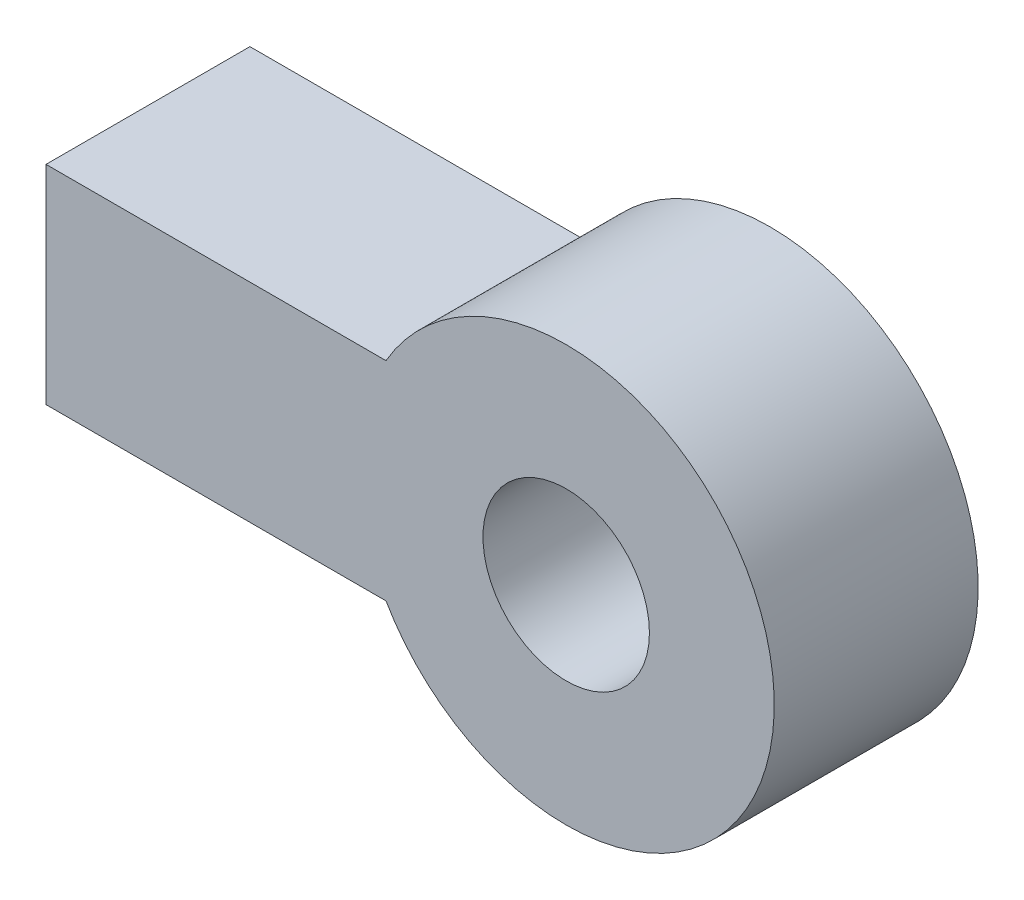
from build123d import *

# Parameters (mm, degrees)
BOSS_EXTRUDE2_DEPTH = 12.446
SKETCH4_R           = 2.54
CUT_EXTRUDE1_DEPTH  = 13.446
SKETCH5_R           = 5.08
CUT_EXTRUDE2_DEPTH  = 10.16


with BuildPart() as part:
    # Sketch3 → Boss-Extrude2 (new body)
    with BuildSketch(Plane.XY):
        with BuildLine():
            Line((-10.998522628, -6.35), (-19.05, -6.35))
            Line((-19.05, -6.35), (-31.75, -6.35))
            Line((-31.75, -6.35), (-31.75, 6.35))
            Line((-31.75, 6.35), (-19.05, 6.35))
            Line((-19.05, 6.35), (-10.998522628, 6.35))
            ThreePointArc((-10.998522628, 6.35), (12.7, 0), (-10.998522628, -6.35))
        make_face()
    extrude(amount=BOSS_EXTRUDE2_DEPTH)

    # Sketch4 → Cut-Extrude1 (cut, through all)
    with BuildSketch(Plane(origin=(0, 0, 0), x_dir=(-1, 0, 0), z_dir=(0, 0, -1))):
        Circle(SKETCH4_R)
    extrude(amount=-CUT_EXTRUDE1_DEPTH, mode=Mode.SUBTRACT)

    # Sketch5 → Cut-Extrude2 (cut)
    with BuildSketch(Plane.XY.offset(12.446)):
        Circle(SKETCH5_R)
    extrude(amount=-CUT_EXTRUDE2_DEPTH, mode=Mode.SUBTRACT)


solid = part.part
